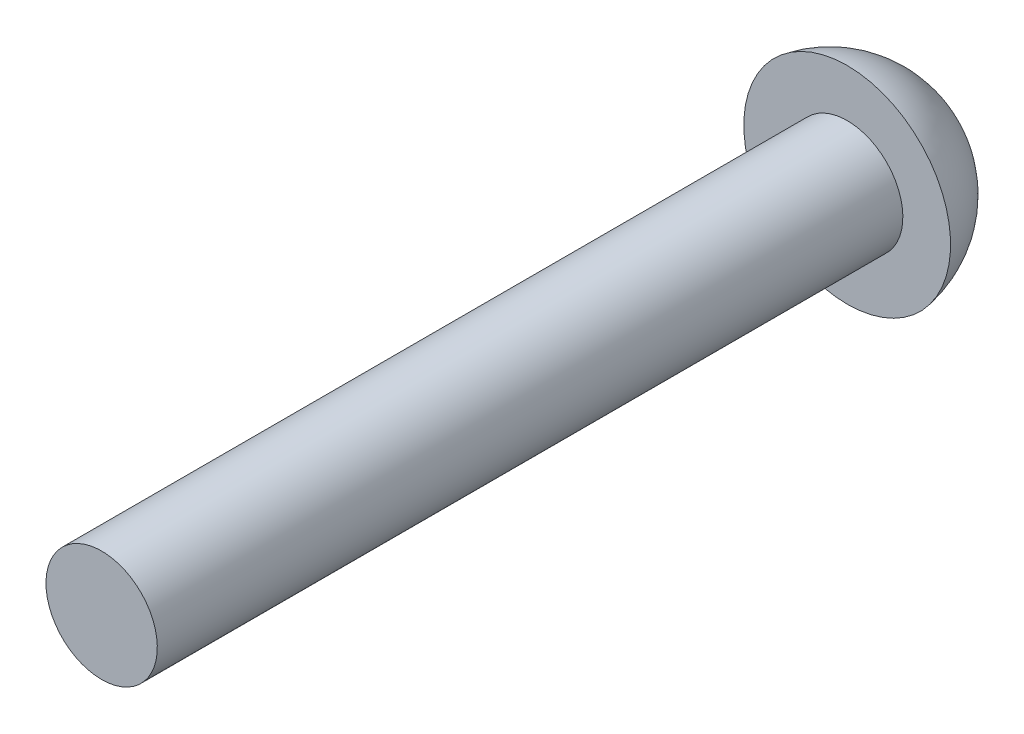
from build123d import *


with BuildPart() as part:
    # Sketch2 → Revolve1 (revolve)
    with BuildSketch(Plane(origin=(0, 0, 0), x_dir=(0, 0, -1), z_dir=(1, 0, 0))):
        with BuildLine():
            Line((0, 0), (0, 1.4224))
            Line((0, 1.4224), (19.05, 1.4224))
            Line((19.05, 1.4224), (19.05, 2.6416))
            ThreePointArc((19.05, 2.6416), (20.65141941, 1.730185655), (21.2852, 0))
            Line((21.2852, 0), (0, 0))
        make_face()
    revolve(axis=Axis((0, 0, 0), (0, 0, -1)))


solid = part.part
